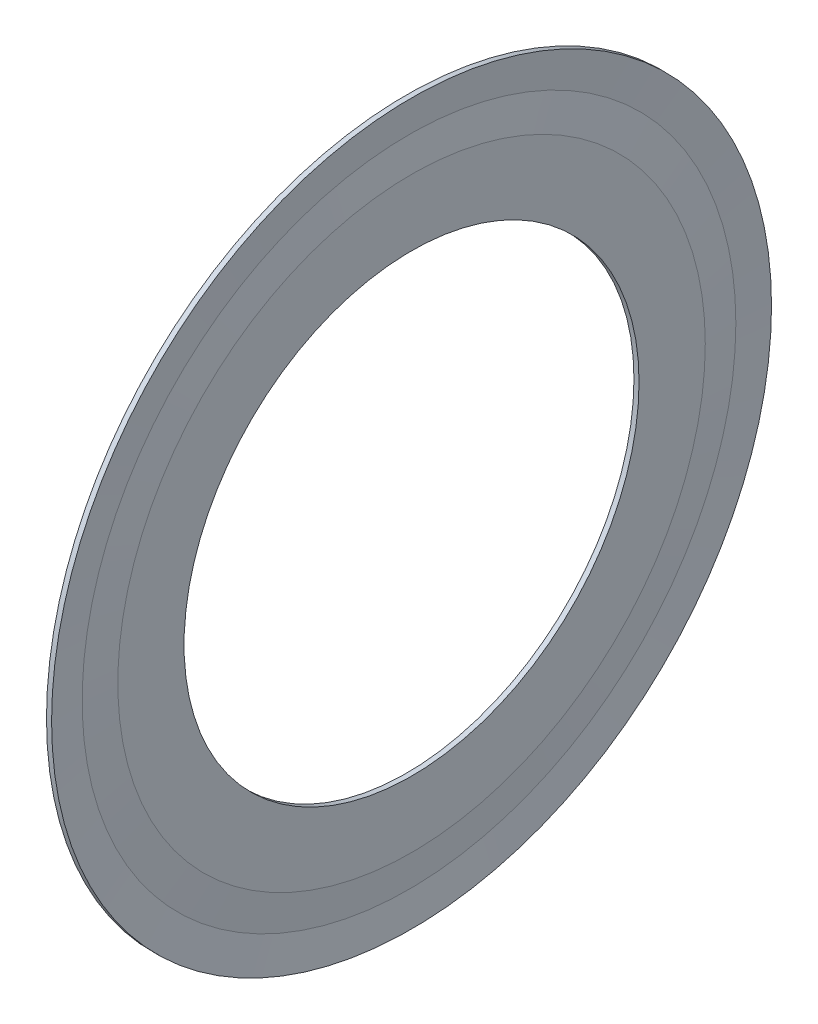
from build123d import *


with BuildPart() as part:
    # Sketch1 → Revolve1 (revolve)
    with BuildSketch(Plane.XY):
        Polygon((13.116, 11.329568043), (13.116, 10.2), (13.293, 7.9), (13.47, 7.9), (13.47, 10.2), (13.3815, 11.35), (13.47, 12.5), (13.293, 12.5), align=None)
    revolve(axis=Axis((50, 0, 0), (-1, 0, 0)))


solid = part.part
